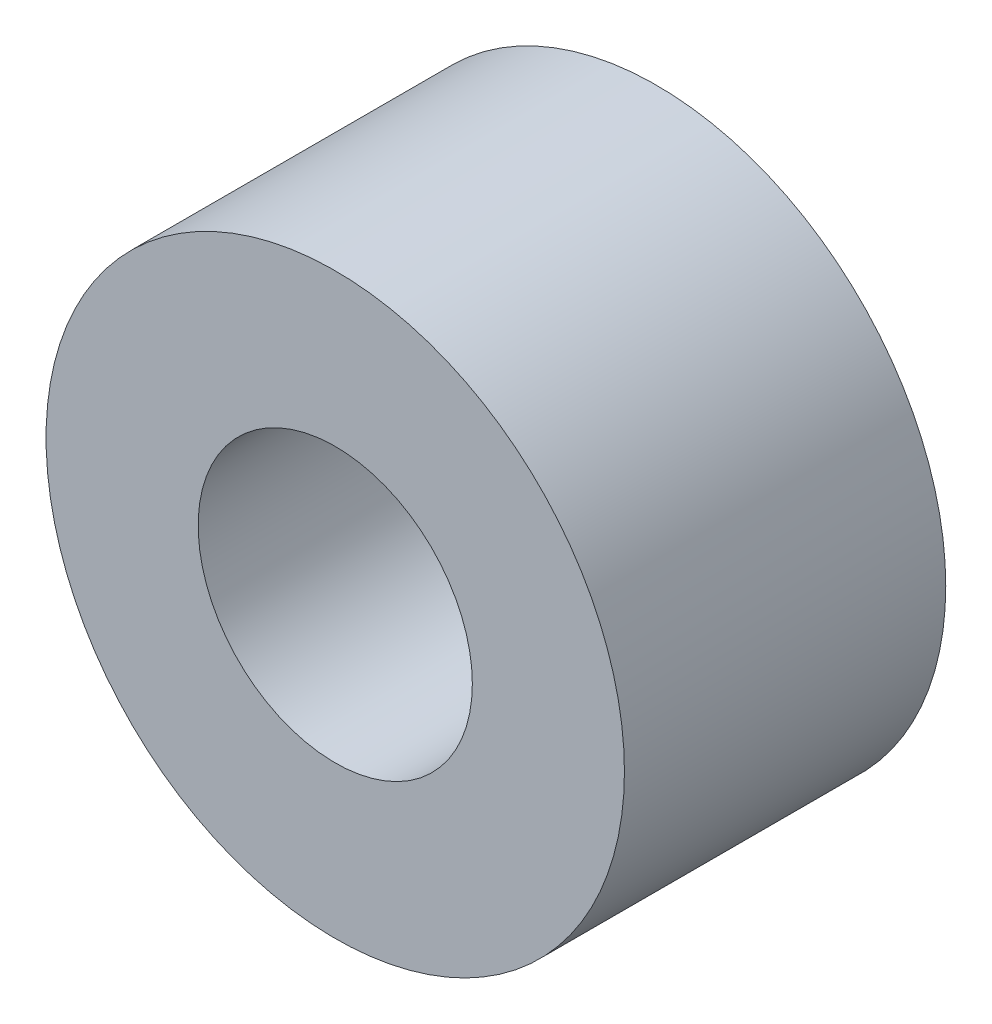
from build123d import *

# Parameters (mm, degrees)
SKETCH1_R           = 4.5
SKETCH1_R_2         = 2.133333333
BOSS_EXTRUDE1_DEPTH = 5


with BuildPart() as part:
    # Sketch1 → Boss-Extrude1 (new body)
    with BuildSketch(Plane.XY):
        Circle(SKETCH1_R)
        Circle(SKETCH1_R_2, mode=Mode.SUBTRACT)
    extrude(amount=BOSS_EXTRUDE1_DEPTH)


solid = part.part
